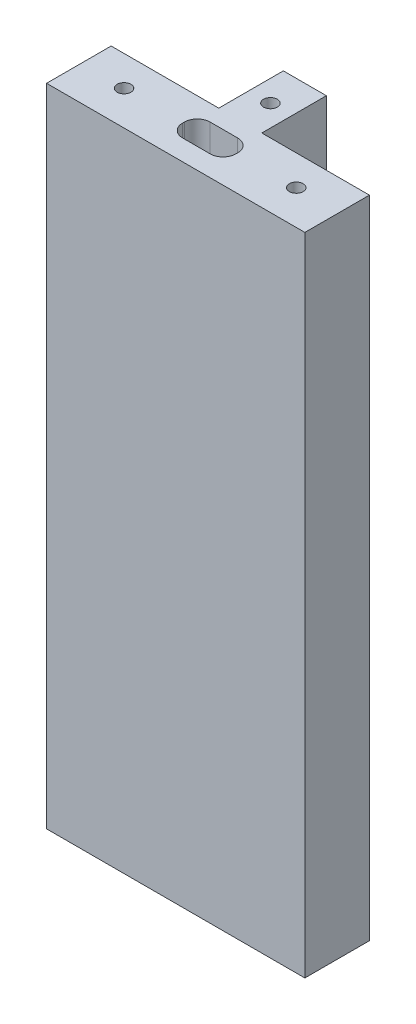
from build123d import *

# Parameters (mm, degrees)
BOSS_EXTRUDE1_DEPTH        = 37.5
SKETCH2_W                  = 6.2
SKETCH2_H                  = 3.2
CUT_EXTRUDE1_DEPTH         = 6.2
FILLET1_R                  = 1.5
M2_TAPPED_HOLE1_AT_2_COUNT = 2
M2_TAPPED_HOLE1_AT_2_PITCH = 12.206555616
M2_TAPPED_HOLE1_AT_3_COUNT = 2
M2_TAPPED_HOLE1_AT_3_PITCH = 20
FILLET1_OF_MIRROR1_R       = 1.5


with BuildPart() as part:
    # Sketch1 → Boss-Extrude1 (new body, symmetric)
    with BuildSketch(Plane(origin=(0, 0, 0), x_dir=(1, 0, 0), z_dir=(0, 1, 0))):
        Polygon((-15, 0), (15, 0), (15, 7.5), (2.5, 7.5), (2.5, 15), (-2.5, 15), (-2.5, 7.5), (-15, 7.5), align=None)
    extrude(amount=BOSS_EXTRUDE1_DEPTH, both=True)

    # Sketch2 → Cut-Extrude1 (cut)
    with BuildSketch(Plane.XZ.offset(37.5)):
        with Locations((0, -4)):
            Rectangle(SKETCH2_W, SKETCH2_H)
    cut_extrude1 = extrude(amount=-CUT_EXTRUDE1_DEPTH, mode=Mode.SUBTRACT)

    # Fillet1
    fillet1_edges = [part.edges().sort_by_distance(p)[0] for p in [
        (-3.1, -34.4, -5.6),
        (-3.1, -34.4, -2.4),
        (3.1, -34.4, -2.4),
        (3.1, -34.4, -5.6),
    ]]
    fillet(fillet1_edges, radius=FILLET1_R)

    # Sketch6 → M2 Tapped Hole1 (revolve, cut)
    with BuildSketch(Plane(origin=(-10, -37.5, -4), x_dir=(0, 0, -1), z_dir=(1, 0, 0))):
        Polygon((0, 0), (0, 5.680688495), (0.8, 5.2), (0.8, 0), align=None)
    m2_tapped_hole1 = revolve(axis=Axis((-10, -43.85, -4), (0, 1, 0)), mode=Mode.SUBTRACT)

    # M2 Tapped Hole1 at 2: M2 Tapped Hole1 ×2
    with Locations(*[Vector(0.819231921, 0, -0.573462344) * (i * M2_TAPPED_HOLE1_AT_2_PITCH) for i in range(1, M2_TAPPED_HOLE1_AT_2_COUNT)]):
        add(m2_tapped_hole1, mode=Mode.SUBTRACT)

    # M2 Tapped Hole1 at 3: M2 Tapped Hole1 ×2
    with Locations(*[(i * M2_TAPPED_HOLE1_AT_3_PITCH, 0, 0) for i in range(1, M2_TAPPED_HOLE1_AT_3_COUNT)]):
        add(m2_tapped_hole1, mode=Mode.SUBTRACT)

    # Mirror1: M2 Tapped Hole1, Cut-Extrude1 across plane
    add(m2_tapped_hole1.mirror(Plane.ZX), mode=Mode.SUBTRACT)
    add(cut_extrude1.mirror(Plane.ZX), mode=Mode.SUBTRACT)

    # Mirror1 copy 1 sketch → Mirror1 copy 1 (revolve, cut)
    with BuildSketch(Plane(origin=(0, 37.5, -11), x_dir=(0, 0, -1), z_dir=(1, 0, 0))):
        Polygon((0, 0), (0, -5.680688495), (0.8, -5.2), (0.8, 0), align=None)
    revolve(axis=Axis((0, 43.85, -11), (0, 1, 0)), mode=Mode.SUBTRACT)

    # Mirror1 copy 2 sketch → Mirror1 copy 2 (revolve, cut)
    with BuildSketch(Plane(origin=(10, 37.5, -4), x_dir=(0, 0, -1), z_dir=(1, 0, 0))):
        Polygon((0, 0), (0, -5.680688495), (0.8, -5.2), (0.8, 0), align=None)
    revolve(axis=Axis((10, 43.85, -4), (0, 1, 0)), mode=Mode.SUBTRACT)

    # Fillet1 of Mirror1
    fillet1_of_mirror1_edges = [part.edges().sort_by_distance(p)[0] for p in [
        (-3.1, 34.4, -5.6),
        (-3.1, 34.4, -2.4),
        (3.1, 34.4, -2.4),
        (3.1, 34.4, -5.6),
    ]]
    fillet(fillet1_of_mirror1_edges, radius=FILLET1_OF_MIRROR1_R)


solid = part.part
